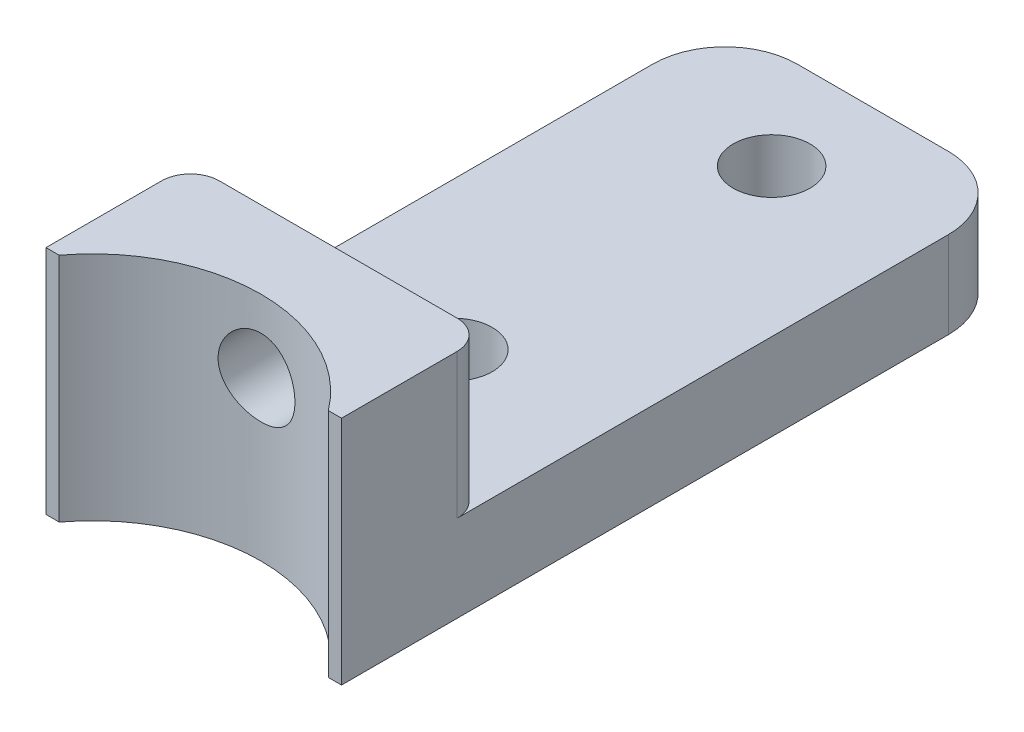
from build123d import *

# Parameters (mm, degrees)
SKETCH1_W                   = 25.978283713
SKETCH1_H                   = 59.69
BOSS_EXTRUDE1_DEPTH         = 7.62
SKETCH2_W                   = 25.978283713
SKETCH2_H                   = 12.7
BOSS_EXTRUDE2_DEPTH         = 12.7
SKETCH4_R                   = 14.7955
CUT_EXTRUDE1_DEPTH          = 20.32
F_1_4_CLEARANCE_HOLE1_D     = 6.7564
F_1_4_CLEARANCE_HOLE1_DEPTH = 7.62
FILLET1_R                   = 6.35
FILLET2_R                   = 2.54
F_1_4_CLEARANCE_HOLE2_D     = 6.7564


with BuildPart() as part:
    # Sketch1 → Boss-Extrude1 (new body)
    with BuildSketch(Plane(origin=(0, 0, 0), x_dir=(1, 0, 0), z_dir=(0, 1, 0))):
        with Locations((12.989141857, 29.845)):
            Rectangle(SKETCH1_W, SKETCH1_H)
    extrude(amount=BOSS_EXTRUDE1_DEPTH)

    # Sketch2 → Boss-Extrude2 (add)
    with BuildSketch(Plane(origin=(0, 7.62, 0), x_dir=(1, 0, 0), z_dir=(0, 1, 0))):
        with Locations((12.989141857, 6.35)):
            Rectangle(SKETCH2_W, SKETCH2_H)
    extrude(amount=BOSS_EXTRUDE2_DEPTH)

    # Sketch4 → Cut-Extrude1 (cut)
    with BuildSketch(Plane(origin=(0, 20.32, 0), x_dir=(1, 0, 0), z_dir=(0, 1, 0))):
        with Locations((12.989141856, -8.89)):
            Circle(SKETCH4_R)
    extrude(amount=-CUT_EXTRUDE1_DEPTH, mode=Mode.SUBTRACT)

    # 1/4 Clearance Hole1
    with Locations(Plane(origin=(0, 7.62, 0), x_dir=(1, 0, 0), z_dir=(0, 1, 0))):
        with Locations((12.989141856, 50.8), (12.989141856, 22.86)):
            Hole(F_1_4_CLEARANCE_HOLE1_D / 2, depth=F_1_4_CLEARANCE_HOLE1_DEPTH)

    # Fillet1
    fillet1_edges = [part.edges().sort_by_distance(p)[0] for p in [
        (0, 3.81, -59.69),
        (25.978283713, 3.81, -59.69),
    ]]
    fillet(fillet1_edges, radius=FILLET1_R)

    # Fillet2
    fillet2_edges = [part.edges().sort_by_distance(p)[0] for p in [
        (0, 13.97, -12.7),
        (25.978283713, 13.97, -12.7),
    ]]
    fillet(fillet2_edges, radius=FILLET2_R)

    # 1/4 Clearance Hole2 (through all)
    with Locations(Plane(origin=(0, 0, -12.7), x_dir=(-1, 0, 0), z_dir=(0, 0, -1))):
        with Locations((-12.989141856, 13.97)):
            Hole(F_1_4_CLEARANCE_HOLE2_D / 2)


solid = part.part
